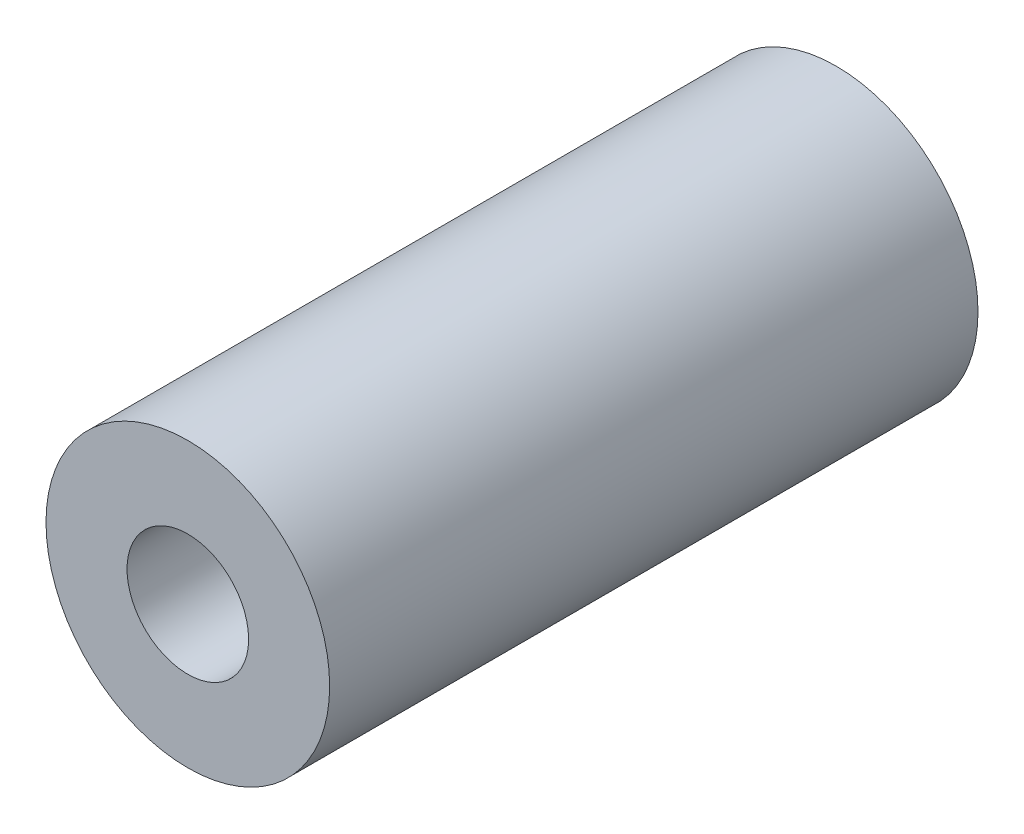
from build123d import *

# Parameters (mm, degrees)
SKETCH1_R           = 11.1125
SKETCH1_R_2         = 4.7625
BOSS_EXTRUDE1_DEPTH = 50.8


with BuildPart() as part:
    # Sketch1 → Boss-Extrude1 (new body)
    with BuildSketch(Plane.XY):
        Circle(SKETCH1_R)
        Circle(SKETCH1_R_2, mode=Mode.SUBTRACT)
    extrude(amount=BOSS_EXTRUDE1_DEPTH)


solid = part.part
